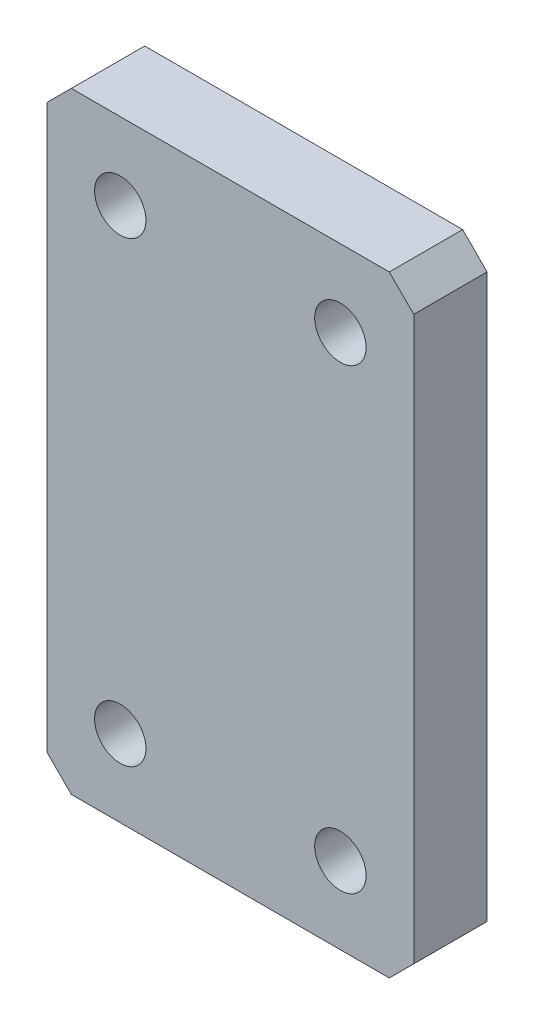
from build123d import *

# Parameters (mm, degrees)
SKETCH1_W             = 30
SKETCH1_H             = 50
BOSS_EXTRUDE1_DEPTH   = 6
M5X0_8_TAPPED_HOLE1_D = 4.2
CHAMFER1_SIZE         = 2


with BuildPart() as part:
    # Sketch1 → Boss-Extrude1 (new body)
    with BuildSketch(Plane.XY):
        with Locations((15, 0)):
            Rectangle(SKETCH1_W, SKETCH1_H)
    extrude(amount=BOSS_EXTRUDE1_DEPTH)

    # M5x0.8 Tapped Hole1 (through all)
    with Locations(Plane.XY.offset(6)):
        with Locations((6, 18.7), (6, -18.7), (24, -18.7), (24, 18.7)):
            Hole(M5X0_8_TAPPED_HOLE1_D / 2)

    # Chamfer1
    chamfer1_edges = [part.edges().sort_by_distance(p)[0] for p in [
        (0, 25, 3),
        (30, 25, 3),
        (30, -25, 3),
        (0, -25, 3),
    ]]
    chamfer(chamfer1_edges, length=CHAMFER1_SIZE)


solid = part.part
